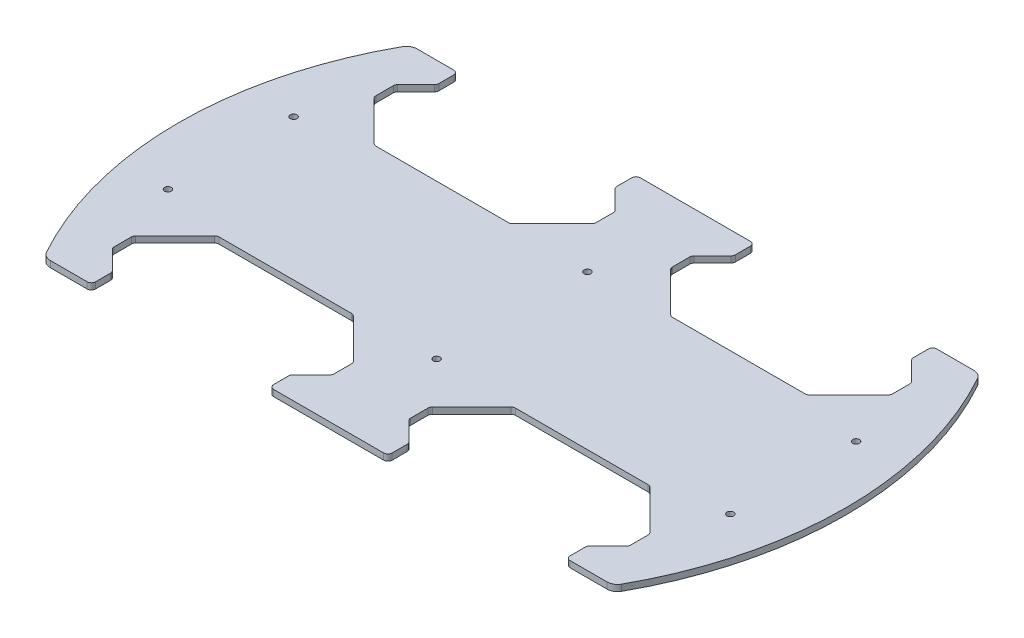
from build123d import *

# Parameters (mm, degrees)
SKETCH1_R           = 1.6
BOSS_EXTRUDE1_DEPTH = 3
FILLET1_R           = 2
FILLET2_R           = 5


with BuildPart() as part:
    # Sketch1 → Boss-Extrude1 (new body)
    with BuildSketch(Plane(origin=(0, 0, 0), x_dir=(1, 0, 0), z_dir=(0, 1, 0))):
        with BuildLine():
            Line((-126.554445662, 87.5), (-104.054445662, 87.5))
            Line((-104.054445662, 87.5), (-104.054445662, 77.5))
            Line((-104.054445662, 77.5), (-114.054445662, 67.5))
            Line((-114.054445662, 67.5), (-114.054445662, 57.5))
            Line((-114.054445662, 57.5), (-94.037011093, 37.482565431))
            Line((-94.037011093, 37.482565431), (-66.537011093, 37.482565431))
            Line((-66.537011093, 37.482565431), (-56.537011093, 37.482565431))
            Line((-56.537011093, 37.482565431), (-29.037011093, 37.482565431))
            Line((-29.037011093, 37.482565431), (-9.054445662, 57.465130862))
            Line((-9.054445662, 57.465130862), (-9.054445662, 67.5))
            Line((-9.054445662, 67.5), (-19.054445662, 77.5))
            Line((-19.054445662, 77.5), (-19.054445662, 87.5))
            Line((-19.054445662, 87.5), (37.5, 87.5))
            Line((37.5, 87.5), (37.5, 77.5))
            Line((37.5, 77.5), (27.5, 67.5))
            Line((27.5, 67.5), (27.5, 57.5))
            Line((27.5, 57.5), (47.5, 37.5))
            Line((47.5, 37.5), (72.157583055, 37.5))
            Line((72.157583055, 37.5), (87.842416945, 37.5))
            Line((87.842416945, 37.5), (112.5, 37.5))
            Line((112.5, 37.5), (132.5, 57.5))
            Line((132.5, 57.5), (132.5, 67.5))
            Line((132.5, 67.5), (122.5, 77.5))
            Line((122.5, 77.5), (122.5, 87.5))
            Line((122.5, 87.5), (136.956007081, 87.5))
            Line((136.956007081, 87.5), (145.020423476, 87.5))
            ThreePointArc((145.020423476, 87.5), (168.465977814, 0), (145.020423476, -87.5))
            Line((145.020423476, -87.5), (136.956007081, -87.5))
            Line((136.956007081, -87.5), (122.5, -87.5))
            Line((122.5, -87.5), (122.5, -77.5))
            Line((122.5, -77.5), (132.5, -67.5))
            Line((132.5, -67.5), (132.5, -57.5))
            Line((132.5, -57.5), (112.5, -37.5))
            Line((112.5, -37.5), (87.842416945, -37.5))
            Line((87.842416945, -37.5), (72.157583055, -37.5))
            Line((72.157583055, -37.5), (47.5, -37.5))
            Line((47.5, -37.5), (27.5, -57.5))
            Line((27.5, -57.5), (27.5, -67.5))
            Line((27.5, -67.5), (37.5, -77.5))
            Line((37.5, -77.5), (37.5, -87.5))
            Line((37.5, -87.5), (-19.054445662, -87.5))
            Line((-19.054445662, -87.5), (-19.054445662, -77.5))
            Line((-19.054445662, -77.5), (-9.054445662, -67.5))
            Line((-9.054445662, -67.5), (-9.054445662, -57.465130862))
            Line((-9.054445662, -57.465130862), (-29.037011093, -37.482565431))
            Line((-29.037011093, -37.482565431), (-56.537011093, -37.482565431))
            Line((-56.537011093, -37.482565431), (-66.537011093, -37.482565431))
            Line((-66.537011093, -37.482565431), (-94.037011093, -37.482565431))
            Line((-94.037011093, -37.482565431), (-114.054445662, -57.5))
            Line((-114.054445662, -57.5), (-114.054445662, -67.5))
            Line((-114.054445662, -67.5), (-104.054445662, -77.5))
            Line((-104.054445662, -77.5), (-104.054445662, -87.5))
            Line((-104.054445662, -87.5), (-126.554445662, -87.5))
            ThreePointArc((-126.554445662, -87.5), (-150, 0), (-126.554445662, 87.5))
        make_face()
        with Locations((-125, -30)):
            Circle(SKETCH1_R, mode=Mode.SUBTRACT)
        with Locations((9.232988907, -36)):
            Circle(SKETCH1_R, mode=Mode.SUBTRACT)
        with Locations((143.46, -30)):
            Circle(SKETCH1_R, mode=Mode.SUBTRACT)
        with Locations((143.46, 30)):
            Circle(SKETCH1_R, mode=Mode.SUBTRACT)
        with Locations((9.232988907, 36)):
            Circle(SKETCH1_R, mode=Mode.SUBTRACT)
        with Locations((-125, 30)):
            Circle(SKETCH1_R, mode=Mode.SUBTRACT)
    extrude(amount=BOSS_EXTRUDE1_DEPTH)

    # Fillet1
    fillet1_edges = [part.edges().sort_by_distance(p)[0] for p in [
        (-104.054445662, 1.5, 87.5),
        (-104.054445662, 1.5, -87.5),
        (-104.054445662, 1.5, -77.5),
        (-114.054445662, 1.5, -67.5),
        (-114.054445662, 1.5, -57.5),
        (-94.037011093, 1.5, -37.482565431),
        (-29.037011093, 1.5, -37.482565431),
        (-9.054445662, 1.5, -57.465130862),
        (-9.054445662, 1.5, -67.5),
        (-19.054445662, 1.5, -77.5),
        (-19.054445662, 1.5, -87.5),
        (37.5, 1.5, -87.5),
        (37.5, 1.5, -77.5),
        (27.5, 1.5, -67.5),
        (27.5, 1.5, -57.5),
        (47.5, 1.5, -37.5),
        (112.5, 1.5, -37.5),
        (132.5, 1.5, -57.5),
        (132.5, 1.5, -67.5),
        (122.5, 1.5, -77.5),
        (122.5, 1.5, -87.5),
        (122.5, 1.5, 87.5),
        (122.5, 1.5, 77.5),
        (132.5, 1.5, 67.5),
        (132.5, 1.5, 57.5),
        (112.5, 1.5, 37.5),
        (47.5, 1.5, 37.5),
        (27.5, 1.5, 57.5),
        (27.5, 1.5, 67.5),
        (37.5, 1.5, 77.5),
        (37.5, 1.5, 87.5),
        (-19.054445662, 1.5, 87.5),
        (-19.054445662, 1.5, 77.5),
        (-9.054445662, 1.5, 67.5),
        (-9.054445662, 1.5, 57.465130862),
        (-29.037011093, 1.5, 37.482565431),
        (-94.037011093, 1.5, 37.482565431),
        (-114.054445662, 1.5, 57.5),
        (-114.054445662, 1.5, 67.5),
        (-104.054445662, 1.5, 77.5),
    ]]
    fillet(fillet1_edges, radius=FILLET1_R)

    # Fillet2
    fillet2_edges = [part.edges().sort_by_distance(p)[0] for p in [
        (-126.554445662, 1.5, 87.5),
        (-126.554445662, 1.5, -87.5),
        (145.020423476, 1.5, -87.5),
        (145.020423476, 1.5, 87.5),
    ]]
    fillet(fillet2_edges, radius=FILLET2_R)


solid = part.part
